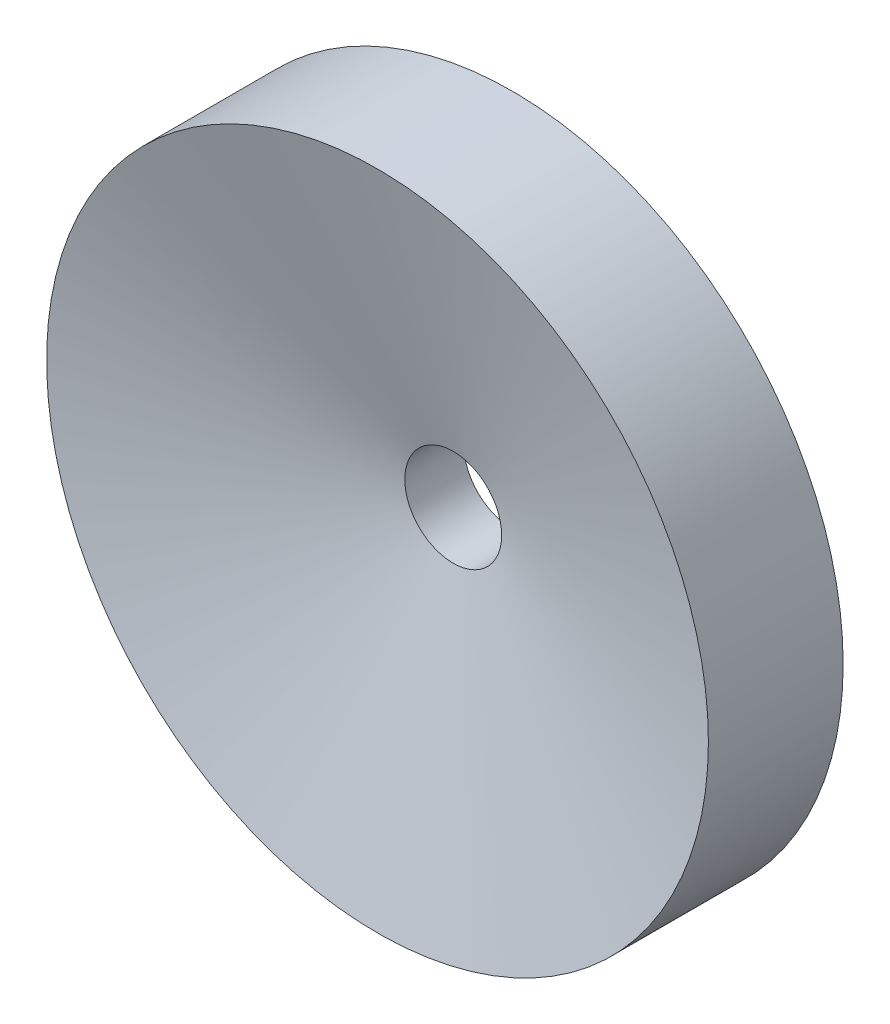
from build123d import *

# Parameters (mm, degrees)
SKETCH_1_R          = 14
EXTRUDE_1_DEPTH     = 2.5
SKETCH_2_R          = 1.45
EXTRUDE_2_DEPTH     = 1.5
SKETCH_3_R          = 2.05
CUT_EXTRUDE_1_DEPTH = 21.199009877


with BuildPart() as part:
    # 草图1 → 凸台-拉伸1 (new body)
    with BuildSketch(Plane.XY):
        Circle(SKETCH_1_R)
    extrude(amount=EXTRUDE_1_DEPTH)

    # 草图2 → 凸台-拉伸2 (add)
    with BuildSketch(Plane(origin=(0, 0, 0), x_dir=(-1, 0, 0), z_dir=(0, 0, -1))):
        with Locations(Location((-9.5, 0, 0), (0, 0, 180))):
            Circle(SKETCH_2_R)
        with Locations(Location((0, 8, 0), (0, 0, 180))):
            Circle(SKETCH_2_R)
        with Locations(Location((0, -8, 0), (0, 0, 180))):
            Circle(SKETCH_2_R)
        with Locations(Location((9.5, 0, 0), (0, 0, 180))):
            Circle(SKETCH_2_R)
    extrude(amount=EXTRUDE_2_DEPTH)

    # 草图3 → 切除-拉伸1 (cut, through all)
    with BuildSketch(Plane.XY.offset(2.5)):
        Circle(SKETCH_3_R)
    extrude(amount=-CUT_EXTRUDE_1_DEPTH, mode=Mode.SUBTRACT)

    # 草图4 → 旋转1 (revolve)
    with BuildSketch(Plane(origin=(0, 0, 0), x_dir=(0, 0, -1), z_dir=(1, 0, 0)), mode=Mode.PRIVATE) as revolve_1_sk:
        Polygon((-2.5, 2.05), (-5.70199285, 14), (-2.5, 14), align=None)
    revolve(revolve_1_sk.sketch.rotate(Axis((0, 0, 14.60459965), (0, 0, -1)), 90), axis=Axis((0, 0, 14.60459965), (0, 0, -1)))


solid = part.part
